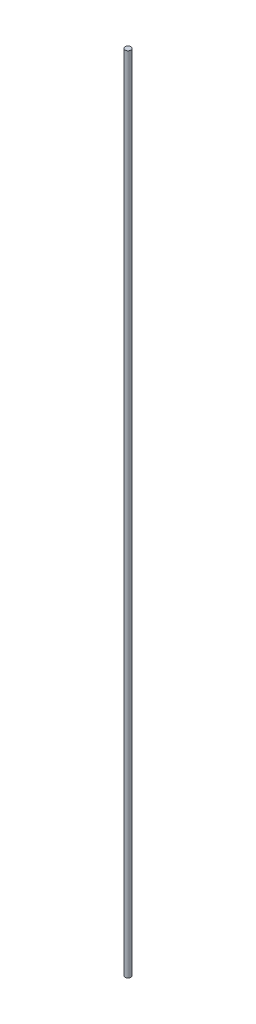
from build123d import *

# Parameters (mm, degrees)
SKETCH_1_R      = 4
EXTRUDE_1_DEPTH = 1092.5


with BuildPart() as part:
    # Эскиз1 → Бобышка-Вытянуть1 (new body)
    with BuildSketch(Plane(origin=(0, 0, 0), x_dir=(1, 0, 0), z_dir=(0, 1, 0))):
        Circle(SKETCH_1_R)
    extrude(amount=EXTRUDE_1_DEPTH)


solid = part.part
